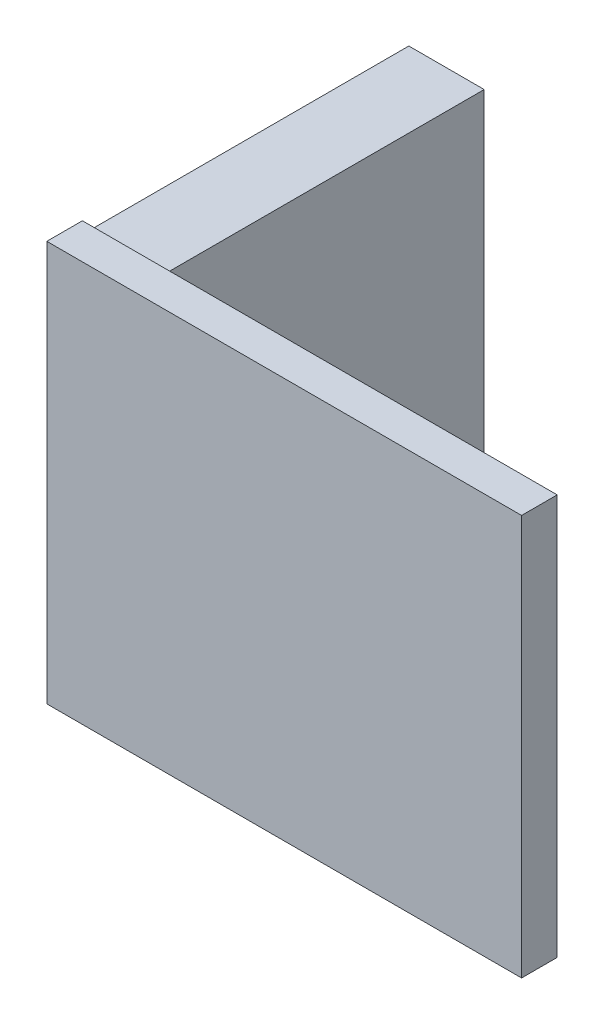
from build123d import *

# Parameters (mm, degrees)
SKETCH_1_W      = 2.54
SKETCH_1_H      = 12.7
EXTRUDE_1_DEPTH = 11
SKETCH_2_W      = 16
SKETCH_2_H      = 13.5
EXTRUDE_2_DEPTH = 1.2


with BuildPart() as part:
    # 草图1 → 凸台-拉伸1 (new body)
    with BuildSketch(Plane.XY):
        with Locations((-65.151130302, 46.101082042)):
            Rectangle(SKETCH_1_W, SKETCH_1_H)
    extrude(amount=EXTRUDE_1_DEPTH)

    # 草图2 → 凸台-拉伸2 (add)
    with BuildSketch(Plane.XY.offset(11)):
        with Locations((-58.421130302, 46.101082042)):
            Rectangle(SKETCH_2_W, SKETCH_2_H)
    extrude(amount=EXTRUDE_2_DEPTH)


solid = part.part
